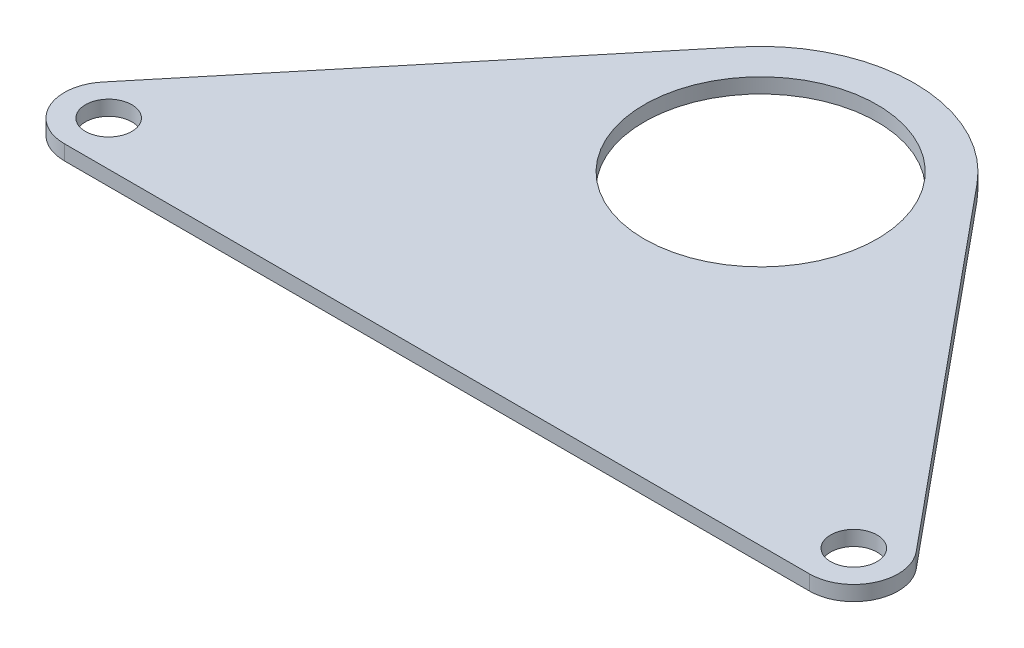
from build123d import *

# Parameters (mm, degrees)
SKETCH1_R                  = 12.5
BOSS_EXTRUDE1_DEPTH        = 1.6002
F_10_CLEARANCE_HOLE1_D     = 4.9784
F_10_CLEARANCE_HOLE1_DEPTH = 172.97
F_10_CLEARANCE_HOLE1_TIP   = 1.495662253


with BuildPart() as part:
    # Sketch1 → Boss-Extrude1 (new body)
    with BuildSketch(Plane(origin=(0, 0, 0), x_dir=(1, 0, 0), z_dir=(0, 1, 0))):
        with BuildLine():
            ThreePointArc((-40, -34.7625), (-44.3084106, -32.029533038), (-43.672046889, -26.967265607))
            Line((-43.672046889, -26.967265607), (-12.722052212, 10.507111283))
            ThreePointArc((-12.722052212, 10.507111283), (0, 16.5), (12.722052212, 10.507111283))
            Line((12.722052212, 10.507111283), (43.672046889, -26.967265607))
            ThreePointArc((43.672046889, -26.967265607), (44.3084106, -32.029533038), (40, -34.7625))
            Line((40, -34.7625), (-40, -34.7625))
        make_face()
        with Locations(Location((0, 0, 0), (0, 0, 270))):  # turned: the seam where the file's is
            Circle(SKETCH1_R, mode=Mode.SUBTRACT)
    extrude(amount=BOSS_EXTRUDE1_DEPTH)

    # #10 Clearance Hole1
    with Locations(Plane(origin=(0, 1.6002, 0), x_dir=(1, 0, 0), z_dir=(0, 1, 0))):
        with Locations((40, -30), (-40, -30)):
            Hole(F_10_CLEARANCE_HOLE1_D / 2, depth=F_10_CLEARANCE_HOLE1_DEPTH)
            with Locations((0, 0, -(F_10_CLEARANCE_HOLE1_DEPTH + F_10_CLEARANCE_HOLE1_TIP / 2))):  # 118° drill point
                Cone(0, F_10_CLEARANCE_HOLE1_D / 2, F_10_CLEARANCE_HOLE1_TIP, mode=Mode.SUBTRACT)


solid = part.part
